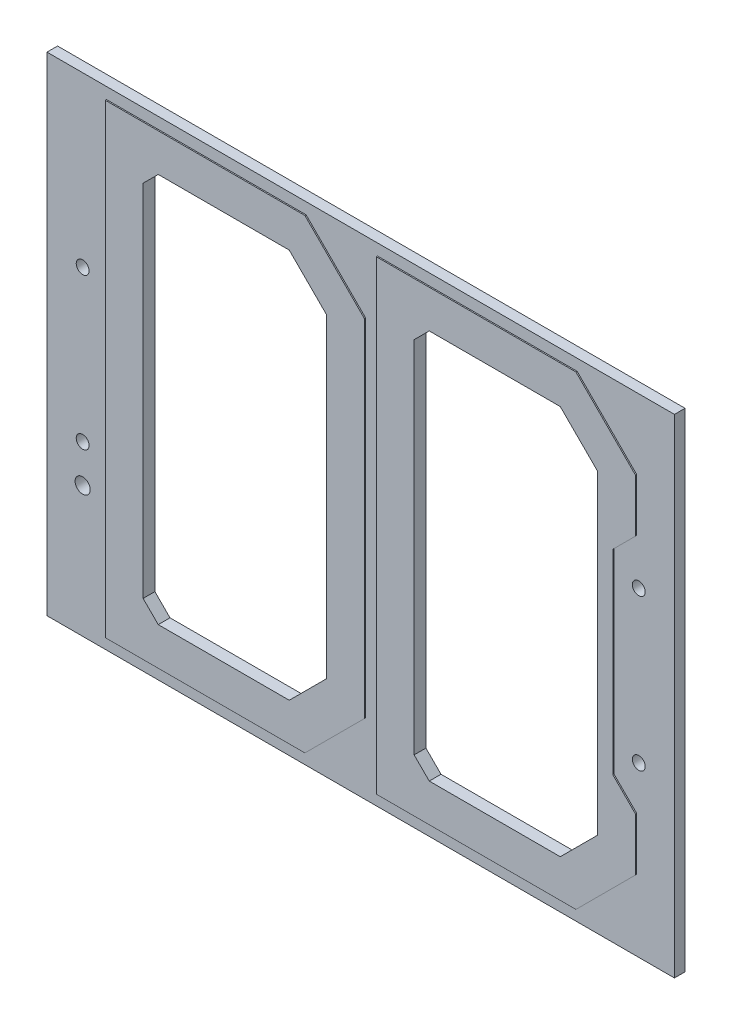
from build123d import *

# Parameters (mm, degrees)
SKETCH1_W           = 105.41
SKETCH1_H           = 82
SKETCH1_R           = 1.0795
SKETCH1_R_2         = 1.27
BOSS_EXTRUDE1_DEPTH = 1.778
BOSS_EXTRUDE2_DEPTH = 0.2
CUT_EXTRUDE1_DEPTH  = 2.978
CHAMFER1_SIZE       = 2.54


with BuildPart() as part:
    # Sketch1 → Boss-Extrude1 (new body)
    with BuildSketch(Plane.XY):
        Rectangle(SKETCH1_W, SKETCH1_H)
        with Locations((46.7106, 12.7)):
            Circle(SKETCH1_R, mode=Mode.SUBTRACT)
        with Locations((46.7106, -12.7)):
            Circle(SKETCH1_R, mode=Mode.SUBTRACT)
        with Locations((-46.7106, 12.7)):
            Circle(SKETCH1_R, mode=Mode.SUBTRACT)
        with Locations((-46.7106, -12.7)):
            Circle(SKETCH1_R, mode=Mode.SUBTRACT)
        with Locations((-46.7106, -19.05)):
            Circle(SKETCH1_R_2, mode=Mode.SUBTRACT)
    extrude(amount=BOSS_EXTRUDE1_DEPTH)

    # Sketch2 → Boss-Extrude2 (add)
    with BuildSketch(Plane.XY.offset(1.778)):
        Polygon((-9.175, 39.095), (0.825, 29.095), (0.825, -29.095), (-9.175, -39.095), (-42.705, -39.095), (-42.705, 39.095), align=None)
        Polygon((46.355, 20.205), (42.545, 16.395), (42.545, -16.395), (46.355, -20.205), (46.355, -29.095), (36.355, -39.095), (2.825, -39.095), (2.825, 39.095), (36.355, 39.095), (46.355, 29.095), align=None)
    extrude(amount=BOSS_EXTRUDE2_DEPTH)

    # Sketch3 → Cut-Extrude1 (cut, through all)
    with BuildSketch(Plane.XY.offset(1.978)):
        Polygon((-36.355, -32.745), (-36.355, 32.745), (-11.805256121, 32.745), (-5.525, 26.464743879), (-5.525, -26.464743879), (-11.805256121, -32.745), align=None)
        Polygon((9.175, -32.745), (9.175, 32.745), (33.724743879, 32.745), (40.005, 26.464743879), (40.005, -26.464743879), (33.724743879, -32.745), align=None)
    extrude(amount=-CUT_EXTRUDE1_DEPTH, mode=Mode.SUBTRACT)

    # Chamfer1
    chamfer1_edges = [part.edges().sort_by_distance(p)[0] for p in [
        (-36.355, -32.745, 0.989),
        (-36.355, 32.745, 0.989),
        (9.175, -32.745, 0.989),
        (9.175, 32.745, 0.989),
    ]]
    chamfer(chamfer1_edges, length=CHAMFER1_SIZE)


solid = part.part
